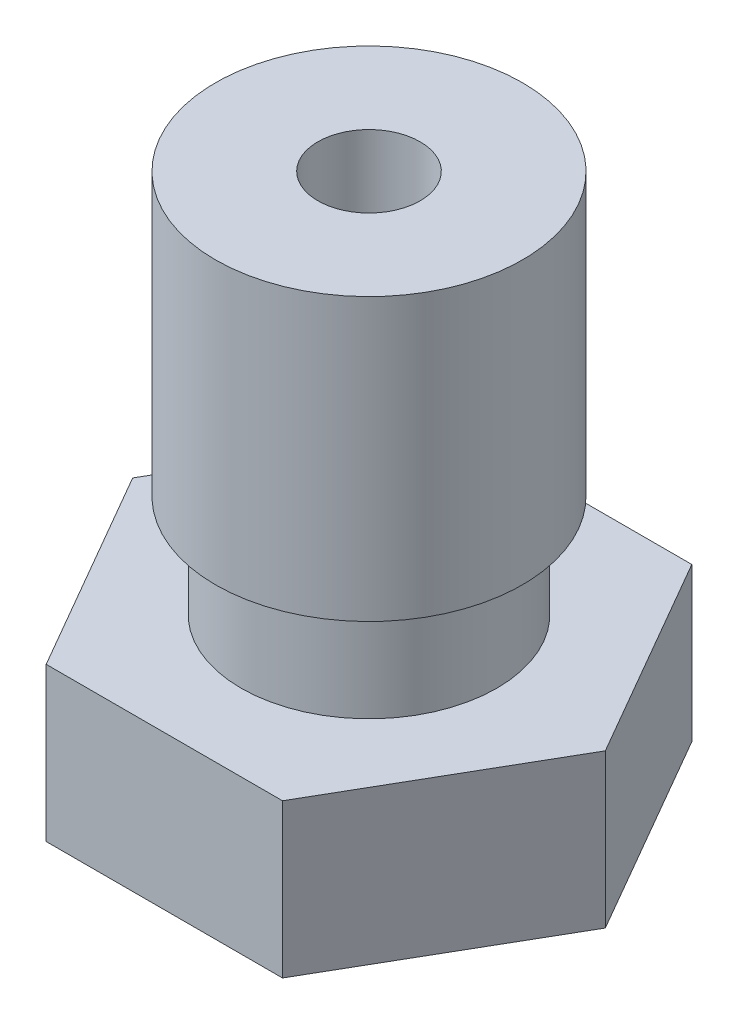
from build123d import *

# Parameters (mm, degrees)
SKETCH1_R           = 1
BOSS_EXTRUDE1_DEPTH = 3


with BuildPart() as part:
    # Sketch1 → Boss-Extrude1 (new body)
    with BuildSketch(Plane(origin=(0, 0, 0), x_dir=(1, 0, 0), z_dir=(0, 1, 0))):
        Polygon((2.309401077, 4), (-2.309401077, 4), (-4.618802154, 0), (-2.309401077, -4), (2.309401077, -4), (4.618802154, 0), align=None)
        Circle(SKETCH1_R, mode=Mode.SUBTRACT)
    extrude(amount=BOSS_EXTRUDE1_DEPTH)

    # Sketch2 → Revolve1 (revolve)
    with BuildSketch(Plane.XY):
        Polygon((2.5, 3), (1, 3), (1, 10.5), (3, 10.5), (3, 5), (2.5, 5), align=None)
        Polygon((1, 0), (2.000415076, 0), (0.6, -2), (0.225, -2), align=None)
    revolve(axis=Axis((0, -2, 0), (0, 1, 0)))


solid = part.part
